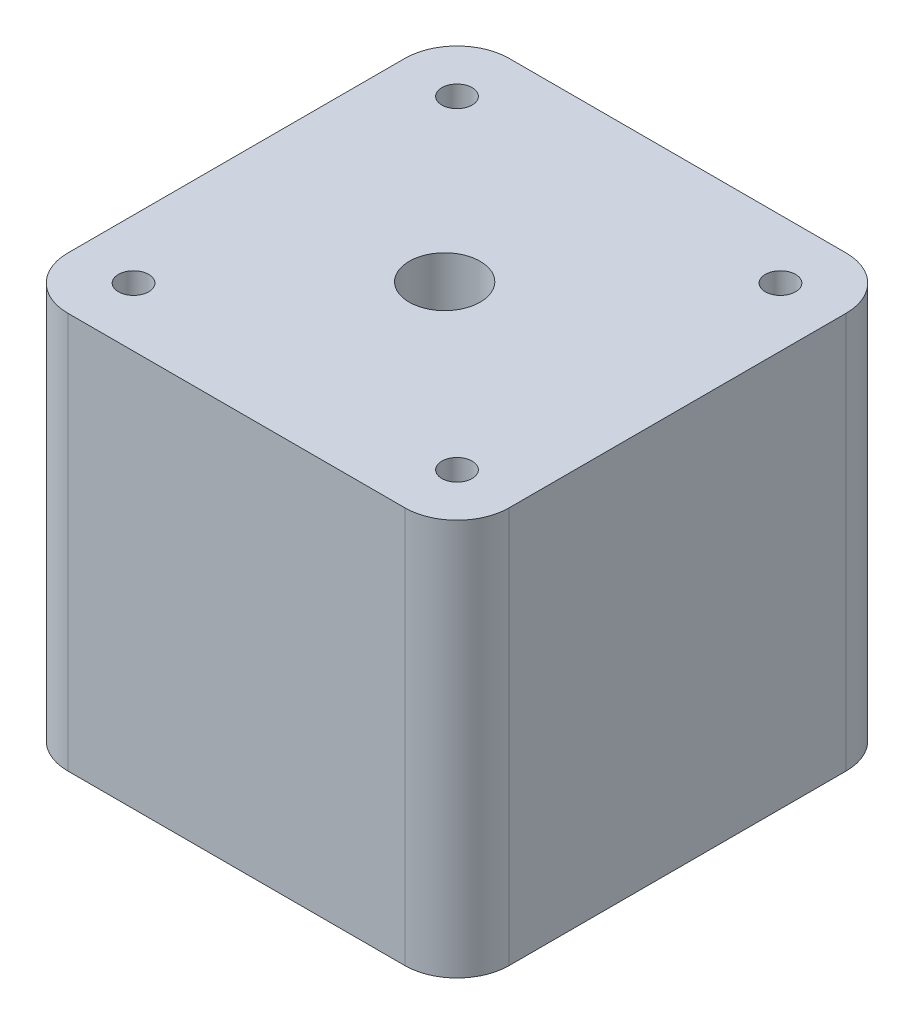
from build123d import *

# Parameters (mm, degrees)
BOSS_EXTRUDE1_DEPTH         = 38
M3_5X0_6_TAPPED_HOLE2_D     = 2.9
M3_5X0_6_TAPPED_HOLE2_DEPTH = 4.5
M3_5X0_6_TAPPED_HOLE2_TIP   = 0.871247898
M8_TAPPED_HOLE1_D           = 6.8


with BuildPart() as part:
    # Sketch2 → Boss-Extrude1 (new body)
    with BuildSketch(Plane(origin=(0, 0, 0), x_dir=(1, 0, 0), z_dir=(0, 1, 0))):
        with BuildLine():
            Line((-22.139889534, 9.97315624), (10.160110466, 9.97315624))
            ThreePointArc((10.160110466, 9.97315624), (13.695644372, 8.508690146), (15.160110466, 4.97315624))
            Line((15.160110466, 4.97315624), (15.160110466, -27.32684376))
            ThreePointArc((15.160110466, -27.32684376), (13.695644372, -30.862377666), (10.160110466, -32.32684376))
            Line((10.160110466, -32.32684376), (-22.139889534, -32.32684376))
            ThreePointArc((-22.139889534, -32.32684376), (-25.67542344, -30.862377666), (-27.139889534, -27.32684376))
            Line((-27.139889534, -27.32684376), (-27.139889534, 4.97315624))
            ThreePointArc((-27.139889534, 4.97315624), (-25.67542344, 8.508690146), (-22.139889534, 9.97315624))
        make_face()
    extrude(amount=BOSS_EXTRUDE1_DEPTH)

    # M3.5x0.6 Tapped Hole2
    with Locations(Plane(origin=(-21.489889534, 38, 26.67684376), x_dir=(0, 0, 1), z_dir=(0, 1, 0))):
        with Locations((0, 0), (-31, 0), (-31, 31), (0, 31)):
            Hole(M3_5X0_6_TAPPED_HOLE2_D / 2, depth=M3_5X0_6_TAPPED_HOLE2_DEPTH)
            with Locations((0, 0, -(M3_5X0_6_TAPPED_HOLE2_DEPTH + M3_5X0_6_TAPPED_HOLE2_TIP / 2))):  # 118° drill point
                Cone(0, M3_5X0_6_TAPPED_HOLE2_D / 2, M3_5X0_6_TAPPED_HOLE2_TIP, mode=Mode.SUBTRACT)

    # M8 Tapped Hole1 (through all)
    with Locations(Plane(origin=(-6.693665392, 38, 11.655067781), x_dir=(0, 0, 1), z_dir=(0, 1, 0))):
        with Locations((0, 0)):
            Hole(M8_TAPPED_HOLE1_D / 2)


solid = part.part
